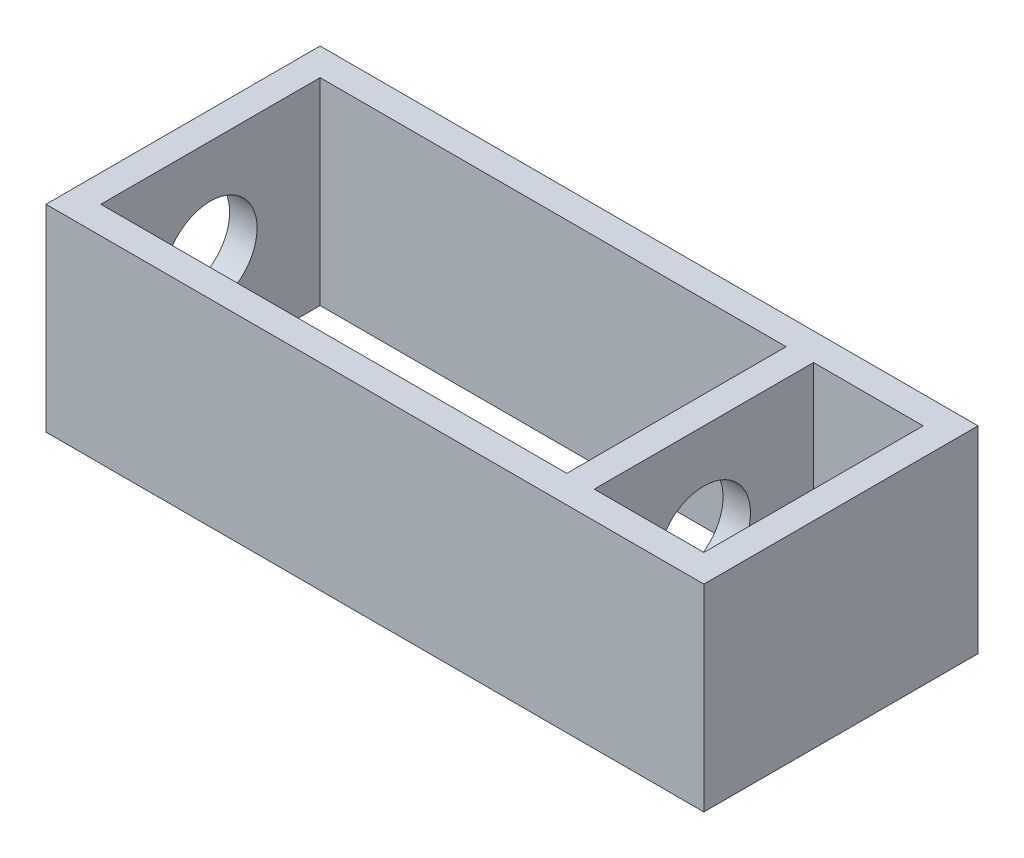
from build123d import *

# Parameters (mm, degrees)
SKETCH1_W           = 60
SKETCH1_H           = 25
SKETCH1_W_2         = 42.5
SKETCH1_H_2         = 20
SKETCH1_W_3         = 10
BOSS_EXTRUDE1_DEPTH = 18
SKETCH3_R           = 4.25
CUT_EXTRUDE1_DEPTH  = 47.5


with BuildPart() as part:
    # Sketch1 → Boss-Extrude1 (new body)
    with BuildSketch(Plane(origin=(0, 0, 0), x_dir=(1, 0, 0), z_dir=(0, 1, 0))):
        with Locations((7.5, 0)):
            Rectangle(SKETCH1_W, SKETCH1_H)
        with Locations((1.25, 0)):
            Rectangle(SKETCH1_W_2, SKETCH1_H_2, mode=Mode.SUBTRACT)
        with Locations((30, 0)):
            Rectangle(SKETCH1_W_3, SKETCH1_H_2, mode=Mode.SUBTRACT)
    extrude(amount=BOSS_EXTRUDE1_DEPTH)

    # Sketch3 → Cut-Extrude1 (cut)
    with BuildSketch(Plane.ZY.offset(22.5)):
        with Locations((0, 9)):
            Circle(SKETCH3_R)
    extrude(amount=-CUT_EXTRUDE1_DEPTH, mode=Mode.SUBTRACT)


solid = part.part
